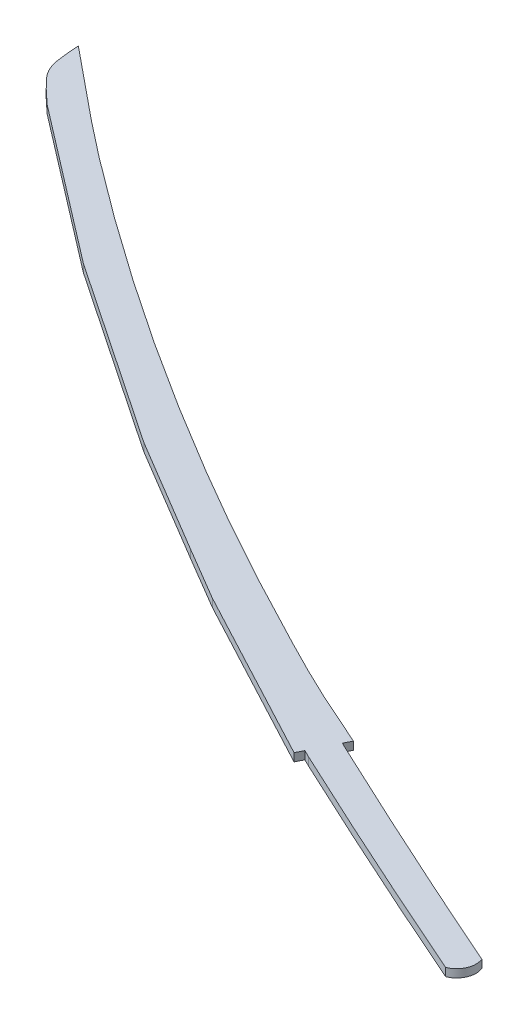
from build123d import *

# Parameters (mm, degrees)
BOSS_EXTRUDE1_DEPTH = 6.35


with BuildPart() as part:
    # Sketch1 → Boss-Extrude1 (new body)
    with BuildSketch(Plane(origin=(0, 0, 0), x_dir=(1, 0, 0), z_dir=(0, 1, 0))):
        with BuildLine():
            Line((402.295387023, -312.337197228), (311.103839714, -257.941008639))
            Line((311.103839714, -257.941008639), (164.740942364, -159.328813556))
            Line((164.740942364, -159.328813556), (42.035523096, -65.198625308))
            add(Edge.make_bspline(
                [(42.035523096, -65.198625308), (34.809254659, -57.783374542), (26.0365703, -51.60990338), (20.356717783, -42.952873009), (14.721899496, -34.364482217), (15.16791571, -22.982537675), (14.219599087, -12.754520804)],
                knots=[0, 0, 0, 0, 1, 1, 1, 2, 2, 2, 2], degree=3))
            add(Edge.make_bspline(
                [(14.219599087, -12.754520804), (41.21910747, -34.552463014), (67.663756504, -57.056155598), (95.218124236, -78.148347433), (189.449612619, -150.280237711), (288.878369987, -215.459882209), (391.89048984, -274.333628813), (427.528344302, -294.701465297), (463.731566552, -314.08818946), (500.215864714, -332.897799272), (519.057164444, -342.611498429), (537.95816821, -352.382232005), (557.250361791, -361.211268777)],
                knots=[0, 0, 0, 0, 1, 1, 1, 2, 2, 2, 3, 3, 3, 3.591984589, 3.591984589, 3.591984589, 3.591984589], degree=3))
            Line((557.250361791, -361.211268777), (597.915791784, -379.31669064))
            Line((597.915791784, -379.31669064), (595.055001706, -385.119531117))
            Line((595.055001706, -385.119531117), (601.081783674, -388.090723953))
            ThreePointArc((601.081783674, -388.090723953), (699.118297106, -433.609317449), (797.743458615, -477.838016696))
            ThreePointArc((797.743458615, -477.838016696), (797.509508056, -489.550122504), (789.06237059, -497.666403916))
            ThreePointArc((789.06237059, -497.666403916), (689.752503897, -453.402545921), (591.036734947, -407.829135827))
            Line((591.036734947, -407.829135827), (585.262595532, -404.982495322))
            Line((585.262595532, -404.982495322), (582.44432277, -410.69909347))
            add(Edge.make_bspline(
                [(444.658128994, -337.369053032), (582.44432277, -410.69909347)],
                knots=[0, 0, 1, 1], degree=1))
            Line((444.658128994, -337.369053032), (402.295387023, -312.337197228))
        make_face()
    extrude(amount=BOSS_EXTRUDE1_DEPTH)


solid = part.part
